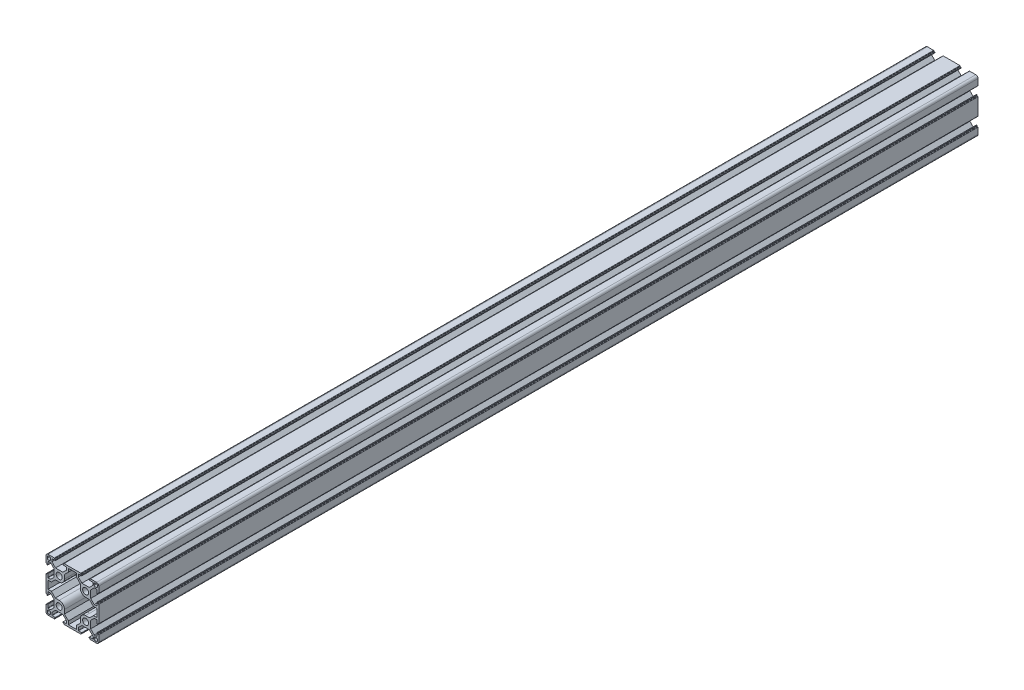
from build123d import *

# Parameters (mm, degrees)
SKETCH_1_R      = 3.4
EXTRUDE_1_DEPTH = 1000


with BuildPart() as part:
    # Эскиз1 → Бобышка-Вытянуть1 (new body)
    with BuildSketch(Plane.XY):
        with BuildLine():
            Line((-30, 23.25), (-30, 27.5))
            ThreePointArc((-30, 27.5), (-29.267766953, 29.267766953), (-27.5, 30))
            Line((-27.5, 30), (-23.25, 30))
            Line((-23.25, 30), (-20.5, 30))
            ThreePointArc((-20.5, 30), (-20.287867966, 29.912132034), (-20.2, 29.7))
            Line((-20.2, 29.7), (-20.2, 29.3))
            ThreePointArc((-20.2, 29.3), (-20.112132034, 29.087867966), (-19.9, 29))
            Line((-19.9, 29), (-19.4, 29))
            ThreePointArc((-19.4, 29), (-19.187867966, 28.912132034), (-19.1, 28.7))
            Line((-19.1, 28.7), (-19.1, 28.3))
            ThreePointArc((-19.1, 28.3), (-19.187867966, 28.087867966), (-19.4, 28))
            Line((-19.4, 28), (-22.95, 28))
            ThreePointArc((-22.95, 28), (-23.162132034, 27.912132034), (-23.25, 27.7))
            Line((-23.25, 27.7), (-23.25, 24.85))
            Line((-23.25, 24.85), (-19.2, 20.8))
            Line((-19.2, 20.8), (-10.8, 20.8))
            Line((-10.8, 20.8), (-6.75, 24.85))
            Line((-6.75, 24.85), (-6.75, 27.7))
            ThreePointArc((-6.75, 27.7), (-6.837867966, 27.912132034), (-7.05, 28))
            Line((-7.05, 28), (-10.6, 28))
            ThreePointArc((-10.6, 28), (-10.812132034, 28.087867966), (-10.9, 28.3))
            Line((-10.9, 28.3), (-10.9, 28.7))
            ThreePointArc((-10.9, 28.7), (-10.812132034, 28.912132034), (-10.6, 29))
            Line((-10.6, 29), (-10.1, 29))
            ThreePointArc((-10.1, 29), (-9.887867966, 29.087867966), (-9.8, 29.3))
            Line((-9.8, 29.3), (-9.8, 29.7))
            ThreePointArc((-9.8, 29.7), (-9.712132034, 29.912132034), (-9.5, 30))
            Line((-9.5, 30), (-6.75, 30))
            Line((-6.75, 30), (6.75, 30))
            Line((6.75, 30), (9.5, 30))
            ThreePointArc((9.5, 30), (9.712132034, 29.912132034), (9.8, 29.7))
            Line((9.8, 29.7), (9.8, 29.3))
            ThreePointArc((9.8, 29.3), (9.887867966, 29.087867966), (10.1, 29))
            Line((10.1, 29), (10.6, 29))
            ThreePointArc((10.6, 29), (10.812132034, 28.912132034), (10.9, 28.7))
            Line((10.9, 28.7), (10.9, 28.3))
            ThreePointArc((10.9, 28.3), (10.812132034, 28.087867966), (10.6, 28))
            Line((10.6, 28), (7.05, 28))
            ThreePointArc((7.05, 28), (6.837867966, 27.912132034), (6.75, 27.7))
            Line((6.75, 27.7), (6.75, 24.85))
            Line((6.75, 24.85), (10.8, 20.8))
            Line((10.8, 20.8), (19.2, 20.8))
            Line((19.2, 20.8), (23.25, 24.85))
            Line((23.25, 24.85), (23.25, 27.7))
            ThreePointArc((23.25, 27.7), (23.162132034, 27.912132034), (22.95, 28))
            Line((22.95, 28), (19.4, 28))
            ThreePointArc((19.4, 28), (19.187867966, 28.087867966), (19.1, 28.3))
            Line((19.1, 28.3), (19.1, 28.7))
            ThreePointArc((19.1, 28.7), (19.187867966, 28.912132034), (19.4, 29))
            Line((19.4, 29), (19.9, 29))
            ThreePointArc((19.9, 29), (20.112132034, 29.087867966), (20.2, 29.3))
            Line((20.2, 29.3), (20.2, 29.7))
            ThreePointArc((20.2, 29.7), (20.287867966, 29.912132034), (20.5, 30))
            Line((20.5, 30), (23.25, 30))
            Line((23.25, 30), (27.5, 30))
            ThreePointArc((27.5, 30), (29.267766953, 29.267766953), (30, 27.5))
            Line((30, 27.5), (30, 23.25))
            Line((30, 23.25), (30, 20.5))
            ThreePointArc((30, 20.5), (29.912132034, 20.287867966), (29.7, 20.2))
            Line((29.7, 20.2), (29.3, 20.2))
            ThreePointArc((29.3, 20.2), (29.087867966, 20.112132034), (29, 19.9))
            Line((29, 19.9), (29, 19.4))
            ThreePointArc((29, 19.4), (28.912132034, 19.187867966), (28.7, 19.1))
            Line((28.7, 19.1), (28.3, 19.1))
            ThreePointArc((28.3, 19.1), (28.087867966, 19.187867966), (28, 19.4))
            Line((28, 19.4), (28, 22.95))
            ThreePointArc((28, 22.95), (27.912132034, 23.162132034), (27.7, 23.25))
            Line((27.7, 23.25), (24.85, 23.25))
            Line((24.85, 23.25), (20.8, 19.2))
            Line((20.8, 19.2), (20.8, 10.8))
            Line((20.8, 10.8), (24.85, 6.75))
            Line((24.85, 6.75), (27.7, 6.75))
            ThreePointArc((27.7, 6.75), (27.912132034, 6.837867966), (28, 7.05))
            Line((28, 7.05), (28, 10.6))
            ThreePointArc((28, 10.6), (28.087867966, 10.812132034), (28.3, 10.9))
            Line((28.3, 10.9), (28.7, 10.9))
            ThreePointArc((28.7, 10.9), (28.912132034, 10.812132034), (29, 10.6))
            Line((29, 10.6), (29, 10.1))
            ThreePointArc((29, 10.1), (29.087867966, 9.887867966), (29.3, 9.8))
            Line((29.3, 9.8), (29.7, 9.8))
            ThreePointArc((29.7, 9.8), (29.912132034, 9.712132034), (30, 9.5))
            Line((30, 9.5), (30, 6.75))
            Line((30, 6.75), (30, -6.75))
            Line((30, -6.75), (30, -9.5))
            ThreePointArc((30, -9.5), (29.912132034, -9.712132034), (29.7, -9.8))
            Line((29.7, -9.8), (29.3, -9.8))
            ThreePointArc((29.3, -9.8), (29.087867966, -9.887867966), (29, -10.1))
            Line((29, -10.1), (29, -10.6))
            ThreePointArc((29, -10.6), (28.912132034, -10.812132034), (28.7, -10.9))
            Line((28.7, -10.9), (28.3, -10.9))
            ThreePointArc((28.3, -10.9), (28.087867966, -10.812132034), (28, -10.6))
            Line((28, -10.6), (28, -7.05))
            ThreePointArc((28, -7.05), (27.912132034, -6.837867966), (27.7, -6.75))
            Line((27.7, -6.75), (24.85, -6.75))
            Line((24.85, -6.75), (20.8, -10.8))
            Line((20.8, -10.8), (20.8, -19.2))
            Line((20.8, -19.2), (24.85, -23.25))
            Line((24.85, -23.25), (27.7, -23.25))
            ThreePointArc((27.7, -23.25), (27.912132034, -23.162132034), (28, -22.95))
            Line((28, -22.95), (28, -19.4))
            ThreePointArc((28, -19.4), (28.087867966, -19.187867966), (28.3, -19.1))
            Line((28.3, -19.1), (28.7, -19.1))
            ThreePointArc((28.7, -19.1), (28.912132034, -19.187867966), (29, -19.4))
            Line((29, -19.4), (29, -19.9))
            ThreePointArc((29, -19.9), (29.087867966, -20.112132034), (29.3, -20.2))
            Line((29.3, -20.2), (29.7, -20.2))
            ThreePointArc((29.7, -20.2), (29.912132034, -20.287867966), (30, -20.5))
            Line((30, -20.5), (30, -23.25))
            Line((30, -23.25), (30, -27.5))
            ThreePointArc((30, -27.5), (29.267766953, -29.267766953), (27.5, -30))
            Line((27.5, -30), (23.25, -30))
            Line((23.25, -30), (20.5, -30))
            ThreePointArc((20.5, -30), (20.287867966, -29.912132034), (20.2, -29.7))
            Line((20.2, -29.7), (20.2, -29.3))
            ThreePointArc((20.2, -29.3), (20.112132034, -29.087867966), (19.9, -29))
            Line((19.9, -29), (19.4, -29))
            ThreePointArc((19.4, -29), (19.187867966, -28.912132034), (19.1, -28.7))
            Line((19.1, -28.7), (19.1, -28.3))
            ThreePointArc((19.1, -28.3), (19.187867966, -28.087867966), (19.4, -28))
            Line((19.4, -28), (22.95, -28))
            ThreePointArc((22.95, -28), (23.162132034, -27.912132034), (23.25, -27.7))
            Line((23.25, -27.7), (23.25, -24.85))
            Line((23.25, -24.85), (19.2, -20.8))
            Line((19.2, -20.8), (10.8, -20.8))
            Line((10.8, -20.8), (6.75, -24.85))
            Line((6.75, -24.85), (6.75, -27.7))
            ThreePointArc((6.75, -27.7), (6.837867966, -27.912132034), (7.05, -28))
            Line((7.05, -28), (10.6, -28))
            ThreePointArc((10.6, -28), (10.812132034, -28.087867966), (10.9, -28.3))
            Line((10.9, -28.3), (10.9, -28.7))
            ThreePointArc((10.9, -28.7), (10.812132034, -28.912132034), (10.6, -29))
            Line((10.6, -29), (10.1, -29))
            ThreePointArc((10.1, -29), (9.887867966, -29.087867966), (9.8, -29.3))
            Line((9.8, -29.3), (9.8, -29.7))
            ThreePointArc((9.8, -29.7), (9.712132034, -29.912132034), (9.5, -30))
            Line((9.5, -30), (6.75, -30))
            Line((6.75, -30), (-6.75, -30))
            Line((-6.75, -30), (-9.5, -30))
            ThreePointArc((-9.5, -30), (-9.712132034, -29.912132034), (-9.8, -29.7))
            Line((-9.8, -29.7), (-9.8, -29.3))
            ThreePointArc((-9.8, -29.3), (-9.887867966, -29.087867966), (-10.1, -29))
            Line((-10.1, -29), (-10.6, -29))
            ThreePointArc((-10.6, -29), (-10.812132034, -28.912132034), (-10.9, -28.7))
            Line((-10.9, -28.7), (-10.9, -28.3))
            ThreePointArc((-10.9, -28.3), (-10.812132034, -28.087867966), (-10.6, -28))
            Line((-10.6, -28), (-7.05, -28))
            ThreePointArc((-7.05, -28), (-6.837867966, -27.912132034), (-6.75, -27.7))
            Line((-6.75, -27.7), (-6.75, -24.85))
            Line((-6.75, -24.85), (-10.8, -20.8))
            Line((-10.8, -20.8), (-19.2, -20.8))
            Line((-19.2, -20.8), (-23.25, -24.85))
            Line((-23.25, -24.85), (-23.25, -27.7))
            ThreePointArc((-23.25, -27.7), (-23.162132034, -27.912132034), (-22.95, -28))
            Line((-22.95, -28), (-19.4, -28))
            ThreePointArc((-19.4, -28), (-19.187867966, -28.087867966), (-19.1, -28.3))
            Line((-19.1, -28.3), (-19.1, -28.7))
            ThreePointArc((-19.1, -28.7), (-19.187867966, -28.912132034), (-19.4, -29))
            Line((-19.4, -29), (-19.9, -29))
            ThreePointArc((-19.9, -29), (-20.112132034, -29.087867966), (-20.2, -29.3))
            Line((-20.2, -29.3), (-20.2, -29.7))
            ThreePointArc((-20.2, -29.7), (-20.287867966, -29.912132034), (-20.5, -30))
            Line((-20.5, -30), (-23.25, -30))
            Line((-23.25, -30), (-27.5, -30))
            ThreePointArc((-27.5, -30), (-29.267766953, -29.267766953), (-30, -27.5))
            Line((-30, -27.5), (-30, -23.25))
            Line((-30, -23.25), (-30, -20.5))
            ThreePointArc((-30, -20.5), (-29.912132034, -20.287867966), (-29.7, -20.2))
            Line((-29.7, -20.2), (-29.3, -20.2))
            ThreePointArc((-29.3, -20.2), (-29.087867966, -20.112132034), (-29, -19.9))
            Line((-29, -19.9), (-29, -19.4))
            ThreePointArc((-29, -19.4), (-28.912132034, -19.187867966), (-28.7, -19.1))
            Line((-28.7, -19.1), (-28.3, -19.1))
            ThreePointArc((-28.3, -19.1), (-28.087867966, -19.187867966), (-28, -19.4))
            Line((-28, -19.4), (-28, -22.95))
            ThreePointArc((-28, -22.95), (-27.912132034, -23.162132034), (-27.7, -23.25))
            Line((-27.7, -23.25), (-24.85, -23.25))
            Line((-24.85, -23.25), (-20.8, -19.2))
            Line((-20.8, -19.2), (-20.8, -10.8))
            Line((-20.8, -10.8), (-24.85, -6.75))
            Line((-24.85, -6.75), (-27.7, -6.75))
            ThreePointArc((-27.7, -6.75), (-27.912132034, -6.837867966), (-28, -7.05))
            Line((-28, -7.05), (-28, -10.6))
            ThreePointArc((-28, -10.6), (-28.087867966, -10.812132034), (-28.3, -10.9))
            Line((-28.3, -10.9), (-28.7, -10.9))
            ThreePointArc((-28.7, -10.9), (-28.912132034, -10.812132034), (-29, -10.6))
            Line((-29, -10.6), (-29, -10.1))
            ThreePointArc((-29, -10.1), (-29.087867966, -9.887867966), (-29.3, -9.8))
            Line((-29.3, -9.8), (-29.7, -9.8))
            ThreePointArc((-29.7, -9.8), (-29.912132034, -9.712132034), (-30, -9.5))
            Line((-30, -9.5), (-30, -6.75))
            Line((-30, -6.75), (-30, 6.75))
            Line((-30, 6.75), (-30, 9.5))
            ThreePointArc((-30, 9.5), (-29.912132034, 9.712132034), (-29.7, 9.8))
            Line((-29.7, 9.8), (-29.3, 9.8))
            ThreePointArc((-29.3, 9.8), (-29.087867966, 9.887867966), (-29, 10.1))
            Line((-29, 10.1), (-29, 10.6))
            ThreePointArc((-29, 10.6), (-28.912132034, 10.812132034), (-28.7, 10.9))
            Line((-28.7, 10.9), (-28.3, 10.9))
            ThreePointArc((-28.3, 10.9), (-28.087867966, 10.812132034), (-28, 10.6))
            Line((-28, 10.6), (-28, 7.05))
            ThreePointArc((-28, 7.05), (-27.912132034, 6.837867966), (-27.7, 6.75))
            Line((-27.7, 6.75), (-24.85, 6.75))
            Line((-24.85, 6.75), (-20.8, 10.8))
            Line((-20.8, 10.8), (-20.8, 19.2))
            Line((-20.8, 19.2), (-24.85, 23.25))
            Line((-24.85, 23.25), (-27.7, 23.25))
            ThreePointArc((-27.7, 23.25), (-27.912132034, 23.162132034), (-28, 22.95))
            Line((-28, 22.95), (-28, 19.4))
            ThreePointArc((-28, 19.4), (-28.087867966, 19.187867966), (-28.3, 19.1))
            Line((-28.3, 19.1), (-28.7, 19.1))
            ThreePointArc((-28.7, 19.1), (-28.912132034, 19.187867966), (-29, 19.4))
            Line((-29, 19.4), (-29, 19.9))
            ThreePointArc((-29, 19.9), (-29.087867966, 20.112132034), (-29.3, 20.2))
            Line((-29.3, 20.2), (-29.7, 20.2))
            ThreePointArc((-29.7, 20.2), (-29.912132034, 20.287867966), (-30, 20.5))
            Line((-30, 20.5), (-30, 23.25))
        make_face()
        with Locations((-15, 15)):
            Circle(SKETCH_1_R, mode=Mode.SUBTRACT)
        with Locations((15, 15)):
            Circle(SKETCH_1_R, mode=Mode.SUBTRACT)
        with Locations((15, -15)):
            Circle(SKETCH_1_R, mode=Mode.SUBTRACT)
        with Locations((-15, -15)):
            Circle(SKETCH_1_R, mode=Mode.SUBTRACT)
        with BuildLine():
            Line((4.5, 27.8), (-4.5, 27.8))
            Line((-4.5, 27.8), (-4.5, 23.988730163))
            Line((-4.5, 23.988730163), (-9, 19.488730163))
            Line((-9, 19.488730163), (-9, 15))
            ThreePointArc((-9, 15), (-10.757359313, 10.757359313), (-15, 9))
            Line((-15, 9), (-19.488730163, 9))
            Line((-19.488730163, 9), (-23.938730163, 4.55))
            Line((-23.938730163, 4.55), (-27.8, 4.55))
            Line((-27.8, 4.55), (-27.8, -4.55))
            Line((-27.8, -4.55), (-23.938730163, -4.55))
            Line((-23.938730163, -4.55), (-19.488730163, -9))
            Line((-19.488730163, -9), (-15, -9))
            ThreePointArc((-15, -9), (-10.757359313, -10.757359313), (-9, -15))
            Line((-9, -15), (-9, -19.488730163))
            Line((-9, -19.488730163), (-4.5, -23.988730163))
            Line((-4.5, -23.988730163), (-4.5, -27.8))
            Line((-4.5, -27.8), (4.5, -27.8))
            Line((4.5, -27.8), (4.5, -23.988730163))
            Line((4.5, -23.988730163), (9, -19.488730163))
            Line((9, -19.488730163), (9, -15))
            ThreePointArc((9, -15), (10.757359313, -10.757359313), (15, -9))
            Line((15, -9), (19.488730163, -9))
            Line((19.488730163, -9), (23.938730163, -4.55))
            Line((23.938730163, -4.55), (27.8, -4.55))
            Line((27.8, -4.55), (27.8, 4.55))
            Line((27.8, 4.55), (23.938730163, 4.55))
            Line((23.938730163, 4.55), (19.488730163, 9))
            Line((19.488730163, 9), (15, 9))
            ThreePointArc((15, 9), (10.757359313, 10.757359313), (9, 15))
            Line((9, 15), (9, 19.488730163))
            Line((9, 19.488730163), (4.5, 23.988730163))
            Line((4.5, 23.988730163), (4.5, 27.8))
        make_face(mode=Mode.SUBTRACT)
        with BuildLine():
            Line((-27.35, 28.55), (-25.95, 28.55))
            ThreePointArc((-25.95, 28.55), (-25.101471863, 28.198528137), (-24.75, 27.35))
            Line((-24.75, 27.35), (-24.75, 25.95))
            ThreePointArc((-24.75, 25.95), (-25.101471863, 25.101471863), (-25.95, 24.75))
            Line((-25.95, 24.75), (-27.35, 24.75))
            ThreePointArc((-27.35, 24.75), (-28.198528137, 25.101471863), (-28.55, 25.95))
            Line((-28.55, 25.95), (-28.55, 27.35))
            ThreePointArc((-28.55, 27.35), (-28.198528137, 28.198528137), (-27.35, 28.55))
        make_face(mode=Mode.SUBTRACT)
        with BuildLine():
            Line((27.35, 28.55), (25.95, 28.55))
            ThreePointArc((25.95, 28.55), (25.101471863, 28.198528137), (24.75, 27.35))
            Line((24.75, 27.35), (24.75, 25.95))
            ThreePointArc((24.75, 25.95), (25.101471863, 25.101471863), (25.95, 24.75))
            Line((25.95, 24.75), (27.35, 24.75))
            ThreePointArc((27.35, 24.75), (28.198528137, 25.101471863), (28.55, 25.95))
            Line((28.55, 25.95), (28.55, 27.35))
            ThreePointArc((28.55, 27.35), (28.198528137, 28.198528137), (27.35, 28.55))
        make_face(mode=Mode.SUBTRACT)
        with BuildLine():
            Line((24.75, -27.35), (24.75, -25.95))
            ThreePointArc((24.75, -25.95), (25.101471863, -25.101471863), (25.95, -24.75))
            Line((25.95, -24.75), (27.35, -24.75))
            ThreePointArc((27.35, -24.75), (28.198528137, -25.101471863), (28.55, -25.95))
            Line((28.55, -25.95), (28.55, -27.35))
            ThreePointArc((28.55, -27.35), (28.198528137, -28.198528137), (27.35, -28.55))
            Line((27.35, -28.55), (25.95, -28.55))
            ThreePointArc((25.95, -28.55), (25.101471863, -28.198528137), (24.75, -27.35))
        make_face(mode=Mode.SUBTRACT)
        with BuildLine():
            Line((-24.75, -27.35), (-24.75, -25.95))
            ThreePointArc((-24.75, -25.95), (-25.101471863, -25.101471863), (-25.95, -24.75))
            Line((-25.95, -24.75), (-27.35, -24.75))
            ThreePointArc((-27.35, -24.75), (-28.198528137, -25.101471863), (-28.55, -25.95))
            Line((-28.55, -25.95), (-28.55, -27.35))
            ThreePointArc((-28.55, -27.35), (-28.198528137, -28.198528137), (-27.35, -28.55))
            Line((-27.35, -28.55), (-25.95, -28.55))
            ThreePointArc((-25.95, -28.55), (-25.101471863, -28.198528137), (-24.75, -27.35))
        make_face(mode=Mode.SUBTRACT)
    extrude(amount=EXTRUDE_1_DEPTH)


solid = part.part
